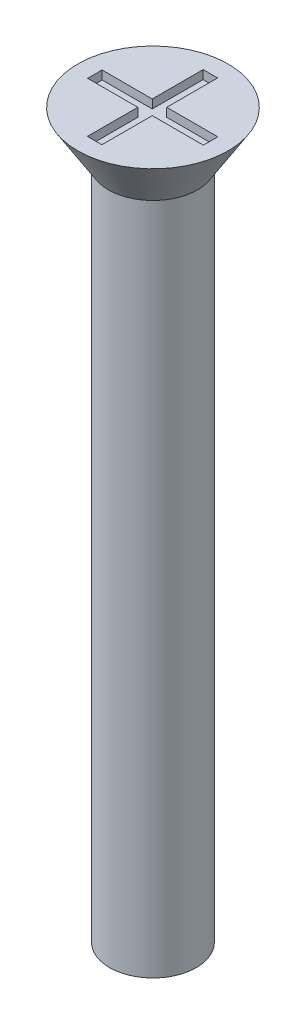
from build123d import *

# Parameters (mm, degrees)
SKETCH1_R           = 1.5
BOSS_EXTRUDE1_DEPTH = 25
SKETCH2_R           = 2.6
BOSS_EXTRUDE2_DEPTH = 1.7
BOSS_EXTRUDE2_TAPER = 32
SKETCH3_W           = 0.5
SKETCH3_H           = 1.758378485
SKETCH3_H_2         = 1.741621515
SKETCH3_W_2         = 1.734727157
SKETCH3_H_3         = 0.5
SKETCH3_W_3         = 1.765272843
CUT_EXTRUDE1_DEPTH  = 0.3


with BuildPart() as part:
    # Sketch1 → Boss-Extrude1 (new body)
    with BuildSketch(Plane(origin=(0, 0, 0), x_dir=(1, 0, 0), z_dir=(0, 1, 0))):
        Circle(SKETCH1_R)
    extrude(amount=BOSS_EXTRUDE1_DEPTH)

    # Sketch2 → Boss-Extrude2 (add)
    with BuildSketch(Plane(origin=(0, 25, 0), x_dir=(1, 0, 0), z_dir=(0, 1, 0))):
        Circle(SKETCH2_R)
    extrude(amount=-BOSS_EXTRUDE2_DEPTH, taper=BOSS_EXTRUDE2_TAPER)

    # Sketch3 → Cut-Extrude1 (cut)
    with BuildSketch(Plane(origin=(0, 25, 0), x_dir=(1, 0, 0), z_dir=(0, 1, 0))):
        with Locations((-0.015272843, 1.120810757)):
            Rectangle(SKETCH3_W, SKETCH3_H)
        with Locations((-0.015272843, -1.129189243)):
            Rectangle(SKETCH3_W, SKETCH3_H_2)
        with Locations((-1.132636421, -0.008378485)):
            Rectangle(SKETCH3_W_2, SKETCH3_H_3)
        with Locations((1.117363579, -0.008378485)):
            Rectangle(SKETCH3_W_3, SKETCH3_H_3)
        with Locations((-0.015272843, -0.008378485)):
            Rectangle(SKETCH3_W, SKETCH3_H_3)
    extrude(amount=-CUT_EXTRUDE1_DEPTH, mode=Mode.SUBTRACT)


solid = part.part
